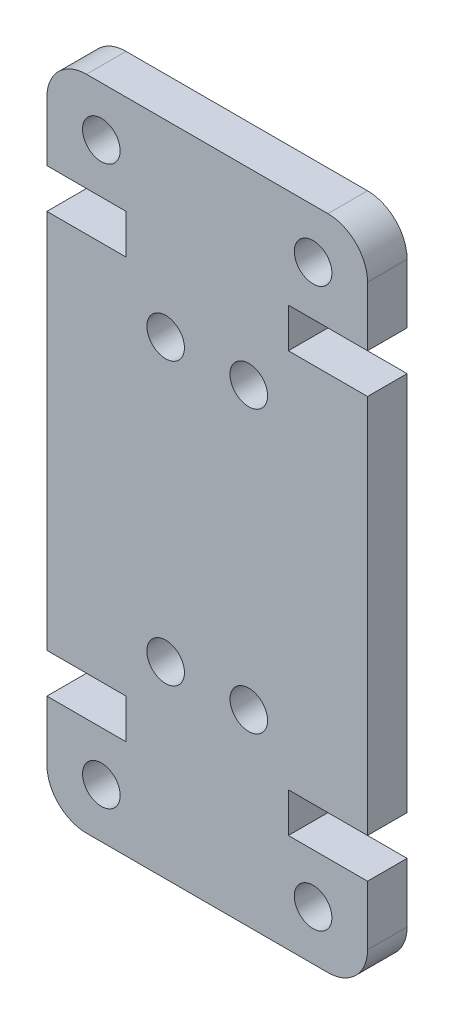
from build123d import *

# Parameters (mm, degrees)
SKETCH1_R           = 0.95
BOSS_EXTRUDE1_DEPTH = 4
SKETCH2_W           = 16.2
SKETCH2_H           = 33.21
CUT_EXTRUDE2_DEPTH  = 2


with BuildPart() as part:
    # Sketch1 → Boss-Extrude1 (new body)
    with BuildSketch(Plane.XY):
        with BuildLine():
            Line((0, 26.21), (0, 7))
            Line((0, 7), (4, 7))
            Line((4, 7), (4, 5))
            Line((4, 5), (0, 5))
            Line((0, 5), (0, 2))
            ThreePointArc((0, 2), (0.585786438, 0.585786438), (2, 0))
            Line((2, 0), (14.2, 0))
            ThreePointArc((14.2, 0), (15.614213562, 0.585786438), (16.2, 2))
            Line((16.2, 2), (16.2, 5))
            Line((16.2, 5), (12.2, 5))
            Line((12.2, 5), (12.2, 7))
            Line((12.2, 7), (16.2, 7))
            Line((16.2, 7), (16.2, 26.21))
            Line((16.2, 26.21), (12.2, 26.21))
            Line((12.2, 26.21), (12.2, 28.21))
            Line((12.2, 28.21), (16.2, 28.21))
            Line((16.2, 28.21), (16.2, 31.21))
            ThreePointArc((16.2, 31.21), (15.614213562, 32.624213562), (14.2, 33.21))
            Line((14.2, 33.21), (2, 33.21))
            ThreePointArc((2, 33.21), (0.585786438, 32.624213562), (0, 31.21))
            Line((0, 31.21), (0, 28.21))
            Line((0, 28.21), (4, 28.21))
            Line((4, 28.21), (4, 26.21))
            Line((4, 26.21), (0, 26.21))
        make_face()
        with Locations((13.45, 2.5)):
            Circle(SKETCH1_R, mode=Mode.SUBTRACT)
        with Locations((10.2, 9.5)):
            Circle(SKETCH1_R, mode=Mode.SUBTRACT)
        with Locations((2.75, 30.71)):
            Circle(SKETCH1_R, mode=Mode.SUBTRACT)
        with Locations((6, 23.71)):
            Circle(SKETCH1_R, mode=Mode.SUBTRACT)
        with Locations((6, 9.5)):
            Circle(SKETCH1_R, mode=Mode.SUBTRACT)
        with Locations((2.75, 2.5)):
            Circle(SKETCH1_R, mode=Mode.SUBTRACT)
        with Locations((10.2, 23.71)):
            Circle(SKETCH1_R, mode=Mode.SUBTRACT)
        with Locations((13.45, 30.71)):
            Circle(SKETCH1_R, mode=Mode.SUBTRACT)
    extrude(amount=BOSS_EXTRUDE1_DEPTH)

    # Sketch2 → Cut-Extrude2 (cut)
    with BuildSketch(Plane.XY):
        with Locations((8.1, 16.605)):
            Rectangle(SKETCH2_W, SKETCH2_H)
    extrude(amount=CUT_EXTRUDE2_DEPTH, mode=Mode.SUBTRACT)


solid = part.part
